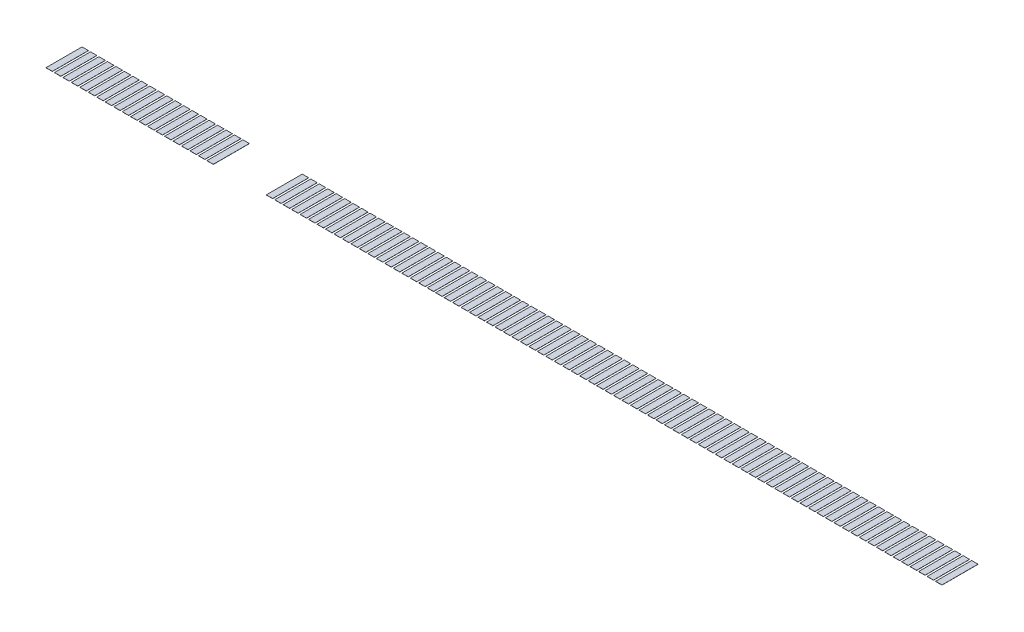
from build123d import *

# Parameters (mm, degrees)
SKETCH_1_W      = 0.45
SKETCH_1_H      = 2.55
EXTRUDE_2_DEPTH = 0.01


with BuildPart() as part:
    # 草图1 → 凸台-拉伸2 (new body)
    with BuildSketch(Plane(origin=(0, 0, 0), x_dir=(1, 0, 0), z_dir=(0, 1, 0))):
        with Locations((0.6, 0)):
            Rectangle(SKETCH_1_W, SKETCH_1_H)
        Rectangle(SKETCH_1_W, SKETCH_1_H)
        with Locations((1.2, 0)):
            Rectangle(SKETCH_1_W, SKETCH_1_H)
        with Locations((1.8, 0)):
            Rectangle(SKETCH_1_W, SKETCH_1_H)
        with Locations((2.4, 0)):
            Rectangle(SKETCH_1_W, SKETCH_1_H)
        with Locations((3, 0)):
            Rectangle(SKETCH_1_W, SKETCH_1_H)
        with Locations((3.6, 0)):
            Rectangle(SKETCH_1_W, SKETCH_1_H)
        with Locations((4.2, 0)):
            Rectangle(SKETCH_1_W, SKETCH_1_H)
        with Locations((4.8, 0)):
            Rectangle(SKETCH_1_W, SKETCH_1_H)
        with Locations((5.4, 0)):
            Rectangle(SKETCH_1_W, SKETCH_1_H)
        with Locations((6, 0)):
            Rectangle(SKETCH_1_W, SKETCH_1_H)
        with Locations((6.6, 0)):
            Rectangle(SKETCH_1_W, SKETCH_1_H)
        with Locations((7.2, 0)):
            Rectangle(SKETCH_1_W, SKETCH_1_H)
        with Locations((7.8, 0)):
            Rectangle(SKETCH_1_W, SKETCH_1_H)
        with Locations((8.4, 0)):
            Rectangle(SKETCH_1_W, SKETCH_1_H)
        with Locations((9, 0)):
            Rectangle(SKETCH_1_W, SKETCH_1_H)
        with Locations((9.6, 0)):
            Rectangle(SKETCH_1_W, SKETCH_1_H)
        with Locations((10.2, 0)):
            Rectangle(SKETCH_1_W, SKETCH_1_H)
        with Locations((10.8, 0)):
            Rectangle(SKETCH_1_W, SKETCH_1_H)
        with Locations((11.4, 0)):
            Rectangle(SKETCH_1_W, SKETCH_1_H)
        with Locations((15.6, 0)):
            Rectangle(SKETCH_1_W, SKETCH_1_H)
        with Locations((16.2, 0)):
            Rectangle(SKETCH_1_W, SKETCH_1_H)
        with Locations((16.8, 0)):
            Rectangle(SKETCH_1_W, SKETCH_1_H)
        with Locations((17.4, 0)):
            Rectangle(SKETCH_1_W, SKETCH_1_H)
        with Locations((18, 0)):
            Rectangle(SKETCH_1_W, SKETCH_1_H)
        with Locations((18.6, 0)):
            Rectangle(SKETCH_1_W, SKETCH_1_H)
        with Locations((19.2, 0)):
            Rectangle(SKETCH_1_W, SKETCH_1_H)
        with Locations((19.8, 0)):
            Rectangle(SKETCH_1_W, SKETCH_1_H)
        with Locations((20.4, 0)):
            Rectangle(SKETCH_1_W, SKETCH_1_H)
        with Locations((21, 0)):
            Rectangle(SKETCH_1_W, SKETCH_1_H)
        with Locations((21.6, 0)):
            Rectangle(SKETCH_1_W, SKETCH_1_H)
        with Locations((22.2, 0)):
            Rectangle(SKETCH_1_W, SKETCH_1_H)
        with Locations((22.8, 0)):
            Rectangle(SKETCH_1_W, SKETCH_1_H)
        with Locations((23.4, 0)):
            Rectangle(SKETCH_1_W, SKETCH_1_H)
        with Locations((24, 0)):
            Rectangle(SKETCH_1_W, SKETCH_1_H)
        with Locations((24.6, 0)):
            Rectangle(SKETCH_1_W, SKETCH_1_H)
        with Locations((25.2, 0)):
            Rectangle(SKETCH_1_W, SKETCH_1_H)
        with Locations((25.8, 0)):
            Rectangle(SKETCH_1_W, SKETCH_1_H)
        with Locations((26.4, 0)):
            Rectangle(SKETCH_1_W, SKETCH_1_H)
        with Locations((27, 0)):
            Rectangle(SKETCH_1_W, SKETCH_1_H)
        with Locations((27.6, 0)):
            Rectangle(SKETCH_1_W, SKETCH_1_H)
        with Locations((28.2, 0)):
            Rectangle(SKETCH_1_W, SKETCH_1_H)
        with Locations((28.8, 0)):
            Rectangle(SKETCH_1_W, SKETCH_1_H)
        with Locations((29.4, 0)):
            Rectangle(SKETCH_1_W, SKETCH_1_H)
        with Locations((30, 0)):
            Rectangle(SKETCH_1_W, SKETCH_1_H)
        with Locations((30.6, 0)):
            Rectangle(SKETCH_1_W, SKETCH_1_H)
        with Locations((31.2, 0)):
            Rectangle(SKETCH_1_W, SKETCH_1_H)
        with Locations((31.8, 0)):
            Rectangle(SKETCH_1_W, SKETCH_1_H)
        with Locations((32.4, 0)):
            Rectangle(SKETCH_1_W, SKETCH_1_H)
        with Locations((33, 0)):
            Rectangle(SKETCH_1_W, SKETCH_1_H)
        with Locations((33.6, 0)):
            Rectangle(SKETCH_1_W, SKETCH_1_H)
        with Locations((34.2, 0)):
            Rectangle(SKETCH_1_W, SKETCH_1_H)
        with Locations((34.8, 0)):
            Rectangle(SKETCH_1_W, SKETCH_1_H)
        with Locations((35.4, 0)):
            Rectangle(SKETCH_1_W, SKETCH_1_H)
        with Locations((36, 0)):
            Rectangle(SKETCH_1_W, SKETCH_1_H)
        with Locations((36.6, 0)):
            Rectangle(SKETCH_1_W, SKETCH_1_H)
        with Locations((37.2, 0)):
            Rectangle(SKETCH_1_W, SKETCH_1_H)
        with Locations((37.8, 0)):
            Rectangle(SKETCH_1_W, SKETCH_1_H)
        with Locations((38.4, 0)):
            Rectangle(SKETCH_1_W, SKETCH_1_H)
        with Locations((39, 0)):
            Rectangle(SKETCH_1_W, SKETCH_1_H)
        with Locations((39.6, 0)):
            Rectangle(SKETCH_1_W, SKETCH_1_H)
        with Locations((40.2, 0)):
            Rectangle(SKETCH_1_W, SKETCH_1_H)
        with Locations((40.8, 0)):
            Rectangle(SKETCH_1_W, SKETCH_1_H)
        with Locations((41.4, 0)):
            Rectangle(SKETCH_1_W, SKETCH_1_H)
        with Locations((42, 0)):
            Rectangle(SKETCH_1_W, SKETCH_1_H)
        with Locations((42.6, 0)):
            Rectangle(SKETCH_1_W, SKETCH_1_H)
        with Locations((43.2, 0)):
            Rectangle(SKETCH_1_W, SKETCH_1_H)
        with Locations((43.8, 0)):
            Rectangle(SKETCH_1_W, SKETCH_1_H)
        with Locations((44.4, 0)):
            Rectangle(SKETCH_1_W, SKETCH_1_H)
        with Locations((45, 0)):
            Rectangle(SKETCH_1_W, SKETCH_1_H)
        with Locations((45.6, 0)):
            Rectangle(SKETCH_1_W, SKETCH_1_H)
        with Locations((46.2, 0)):
            Rectangle(SKETCH_1_W, SKETCH_1_H)
        with Locations((46.8, 0)):
            Rectangle(SKETCH_1_W, SKETCH_1_H)
        with Locations((47.4, 0)):
            Rectangle(SKETCH_1_W, SKETCH_1_H)
        with Locations((48, 0)):
            Rectangle(SKETCH_1_W, SKETCH_1_H)
        with Locations((48.6, 0)):
            Rectangle(SKETCH_1_W, SKETCH_1_H)
        with Locations((49.2, 0)):
            Rectangle(SKETCH_1_W, SKETCH_1_H)
        with Locations((49.8, 0)):
            Rectangle(SKETCH_1_W, SKETCH_1_H)
        with Locations((50.4, 0)):
            Rectangle(SKETCH_1_W, SKETCH_1_H)
        with Locations((51, 0)):
            Rectangle(SKETCH_1_W, SKETCH_1_H)
        with Locations((51.6, 0)):
            Rectangle(SKETCH_1_W, SKETCH_1_H)
        with Locations((52.2, 0)):
            Rectangle(SKETCH_1_W, SKETCH_1_H)
        with Locations((52.8, 0)):
            Rectangle(SKETCH_1_W, SKETCH_1_H)
        with Locations((53.4, 0)):
            Rectangle(SKETCH_1_W, SKETCH_1_H)
        with Locations((54, 0)):
            Rectangle(SKETCH_1_W, SKETCH_1_H)
        with Locations((54.6, 0)):
            Rectangle(SKETCH_1_W, SKETCH_1_H)
        with Locations((55.2, 0)):
            Rectangle(SKETCH_1_W, SKETCH_1_H)
        with Locations((55.8, 0)):
            Rectangle(SKETCH_1_W, SKETCH_1_H)
        with Locations((56.4, 0)):
            Rectangle(SKETCH_1_W, SKETCH_1_H)
        with Locations((57, 0)):
            Rectangle(SKETCH_1_W, SKETCH_1_H)
        with Locations((57.6, 0)):
            Rectangle(SKETCH_1_W, SKETCH_1_H)
        with Locations((58.2, 0)):
            Rectangle(SKETCH_1_W, SKETCH_1_H)
        with Locations((58.8, 0)):
            Rectangle(SKETCH_1_W, SKETCH_1_H)
        with Locations((59.4, 0)):
            Rectangle(SKETCH_1_W, SKETCH_1_H)
        with Locations((60, 0)):
            Rectangle(SKETCH_1_W, SKETCH_1_H)
        with Locations((60.6, 0)):
            Rectangle(SKETCH_1_W, SKETCH_1_H)
        with Locations((61.2, 0)):
            Rectangle(SKETCH_1_W, SKETCH_1_H)
        with Locations((61.8, 0)):
            Rectangle(SKETCH_1_W, SKETCH_1_H)
        with Locations((62.4, 0)):
            Rectangle(SKETCH_1_W, SKETCH_1_H)
        with Locations((63, 0)):
            Rectangle(SKETCH_1_W, SKETCH_1_H)
    extrude(amount=-EXTRUDE_2_DEPTH)


solid = part.part
